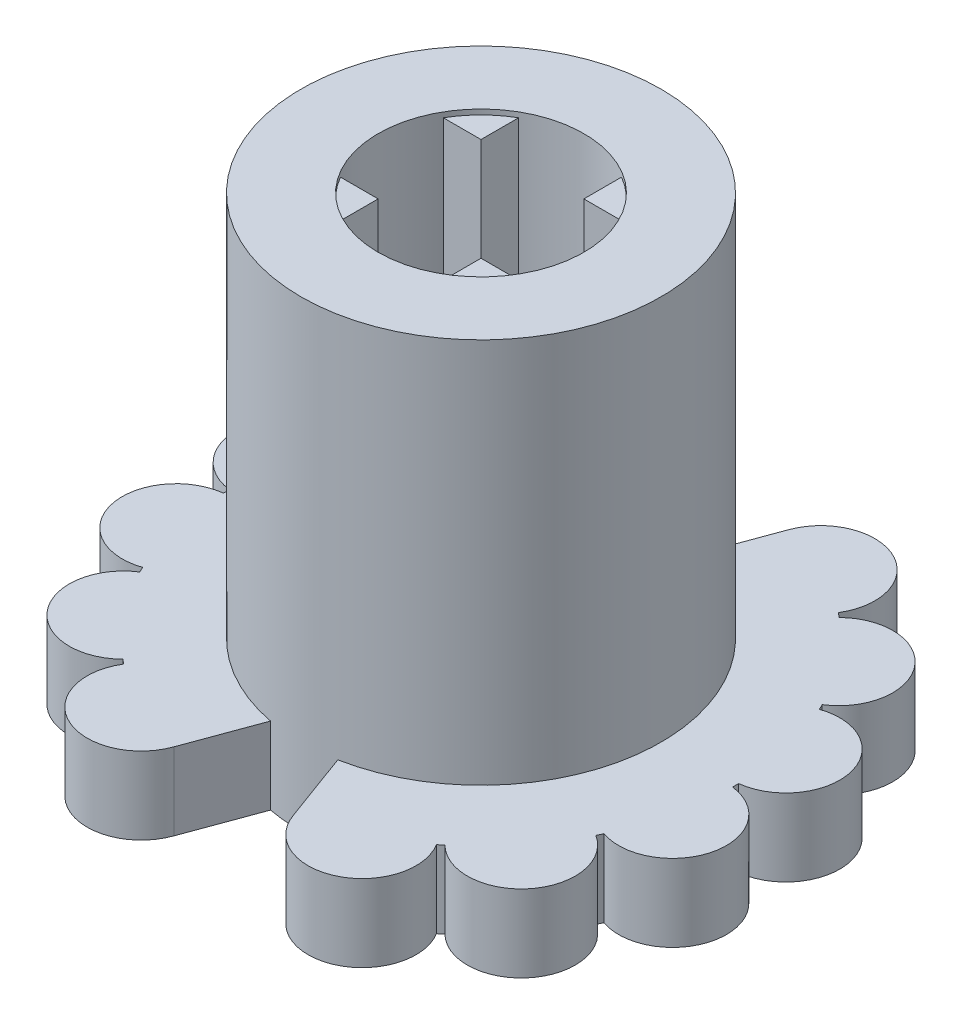
from build123d import *

# Parameters (mm, degrees)
SKETCH1_R               = 1.05
SKETCH1_R_2             = 4.95
BOSS_EXTRUDE1_DEPTH     = 1.5
CIRPATTERN1_COUNT       = 14
SKETCH2_R               = 3.5
SKETCH2_R_2             = 2
SKETCH2_W               = 2
SKETCH2_H               = 4
SKETCH2_W_2             = 4
SKETCH2_H_2             = 2
BOSS_EXTRUDE2_DEPTH     = 7.5
SKETCH3_R               = 2
CUT_EXTRUDE1_DEPTH      = 0.1
SKETCH4_R               = 1
CUT_EXTRUDE2_DEPTH      = 1
CUT_EXTRUDE3_DEPTH      = 1
CUT_EXTRUDE3_DEPTH_BACK = 10


with BuildPart() as part:
    # Sketch1 → Boss-Extrude1 (new body)
    with BuildSketch(Plane(origin=(0, 0, 0), x_dir=(1, 0, 0), z_dir=(0, 1, 0))):
        with Locations((0, 4.95)):
            Circle(SKETCH1_R)
        Circle(SKETCH1_R_2)
    boss_extrude1 = extrude(amount=BOSS_EXTRUDE1_DEPTH)

    # CirPattern1: Boss-Extrude1 ×14 about axis
    cirpattern1_axis = Axis((0, 0, 0), (0, 1, 0))
    for i in range(1, CIRPATTERN1_COUNT):
        add(boss_extrude1.rotate(cirpattern1_axis, i * 360 / CIRPATTERN1_COUNT))

    # Sketch2 → Boss-Extrude2 (add)
    with BuildSketch(Plane(origin=(0, 1.5, 0), x_dir=(1, 0, 0), z_dir=(0, 1, 0))):
        Circle(SKETCH2_R)
        Circle(SKETCH2_R_2, mode=Mode.SUBTRACT)
        Rectangle(SKETCH2_W, SKETCH2_H, mode=Mode.SUBTRACT)
        Rectangle(SKETCH2_W_2, SKETCH2_H_2, mode=Mode.SUBTRACT)
        with BuildLine():
            ThreePointArc((-1, 1.732050808), (-0.517638086, 1.931851654), (9e-09, 2))
            Line((9e-09, 2), (-1, 2))
            Line((-1, 2), (-1, 1.732050808))
        make_face()
        with BuildLine():
            Line((1, 1.732050808), (1, 2))
            Line((1, 2), (9e-09, 2))
            ThreePointArc((9e-09, 2), (0.517638095, 1.931851651), (1, 1.732050808))
        make_face()
        with BuildLine():
            Line((2, 1), (1.732050808, 1))
            ThreePointArc((1.732050808, 1), (1.931851653, 0.51763809), (2, 0))
            Line((2, 0), (2, 1))
        make_face()
        with BuildLine():
            ThreePointArc((1.732050808, 1), (1.414213562, 1.414213562), (1, 1.732050808))
            Line((1, 1.732050808), (1, 1))
            Line((1, 1), (1.732050808, 1))
        make_face()
        with BuildLine():
            Line((-1, 1), (-1, 1.732050808))
            ThreePointArc((-1, 1.732050808), (-1.414213562, 1.414213562), (-1.732050808, 1))
            Line((-1.732050808, 1), (-1, 1))
        make_face()
        with BuildLine():
            ThreePointArc((-2, 0), (-1.931851653, 0.51763809), (-1.732050808, 1))
            Line((-1.732050808, 1), (-2, 1))
            Line((-2, 1), (-2, 0))
        make_face()
        with BuildLine():
            ThreePointArc((-1.732050808, -1), (-1.931851653, -0.51763809), (-2, 0))
            Line((-2, 0), (-2, -1))
            Line((-2, -1), (-1.732050808, -1))
        make_face()
        with BuildLine():
            Line((-1, -1.732050808), (-1, -1))
            Line((-1, -1), (-1.732050808, -1))
            ThreePointArc((-1.732050808, -1), (-1.414213562, -1.414213562), (-1, -1.732050808))
        make_face()
        with BuildLine():
            ThreePointArc((0, -2), (-0.51763809, -1.931851653), (-1, -1.732050808))
            Line((-1, -1.732050808), (-1, -2))
            Line((-1, -2), (0, -2))
        make_face()
        with BuildLine():
            Line((1, -2), (1, -1.732050808))
            ThreePointArc((1, -1.732050808), (0.51763809, -1.931851653), (0, -2))
            Line((0, -2), (1, -2))
        make_face()
        with BuildLine():
            Line((1.732050808, -1), (1, -1))
            Line((1, -1), (1, -1.732050808))
            ThreePointArc((1, -1.732050808), (1.414213562, -1.414213562), (1.732050808, -1))
        make_face()
        with BuildLine():
            Line((2, -1), (2, 0))
            ThreePointArc((2, 0), (1.931851653, -0.51763809), (1.732050808, -1))
            Line((1.732050808, -1), (2, -1))
        make_face()
    extrude(amount=BOSS_EXTRUDE2_DEPTH)

    # Sketch3 → Cut-Extrude1 (cut)
    with BuildSketch(Plane(origin=(0, 9, 0), x_dir=(1, 0, 0), z_dir=(0, 1, 0))):
        Circle(SKETCH3_R)
    extrude(amount=-CUT_EXTRUDE1_DEPTH, mode=Mode.SUBTRACT)

    # Sketch4 → Cut-Extrude2 (cut)
    with BuildSketch(Plane.XZ):
        Circle(SKETCH4_R)
    extrude(amount=-CUT_EXTRUDE2_DEPTH, mode=Mode.SUBTRACT)

    # Sketch5 → Cut-Extrude3 (cut, two sides)
    with BuildSketch(Plane(origin=(0, 9, 0), x_dir=(1, 0, 0), z_dir=(0, 1, 0))) as cut_extrude3_sk:
        with BuildLine():
            Line((-1.594989552, 6), (1.594989552, 6))
            Line((1.594989552, 6), (0.653815854, 3.43838986))
            ThreePointArc((0.653815854, 3.43838986), (0, 3.5), (-0.653815854, 3.43838986))
            Line((-0.653815854, 3.43838986), (-1.594989552, 6))
        make_face()
        with BuildLine():
            Line((1.594989552, -6), (0.653815854, -3.43838986))
            ThreePointArc((0.653815854, -3.43838986), (0, -3.5), (-0.653815854, -3.43838986))
            Line((-0.653815854, -3.43838986), (-1.594989552, -6))
            Line((-1.594989552, -6), (1.594989552, -6))
        make_face()
    extrude(amount=CUT_EXTRUDE3_DEPTH, mode=Mode.SUBTRACT)
    extrude(cut_extrude3_sk.sketch, amount=-CUT_EXTRUDE3_DEPTH_BACK, mode=Mode.SUBTRACT)


solid = part.part
